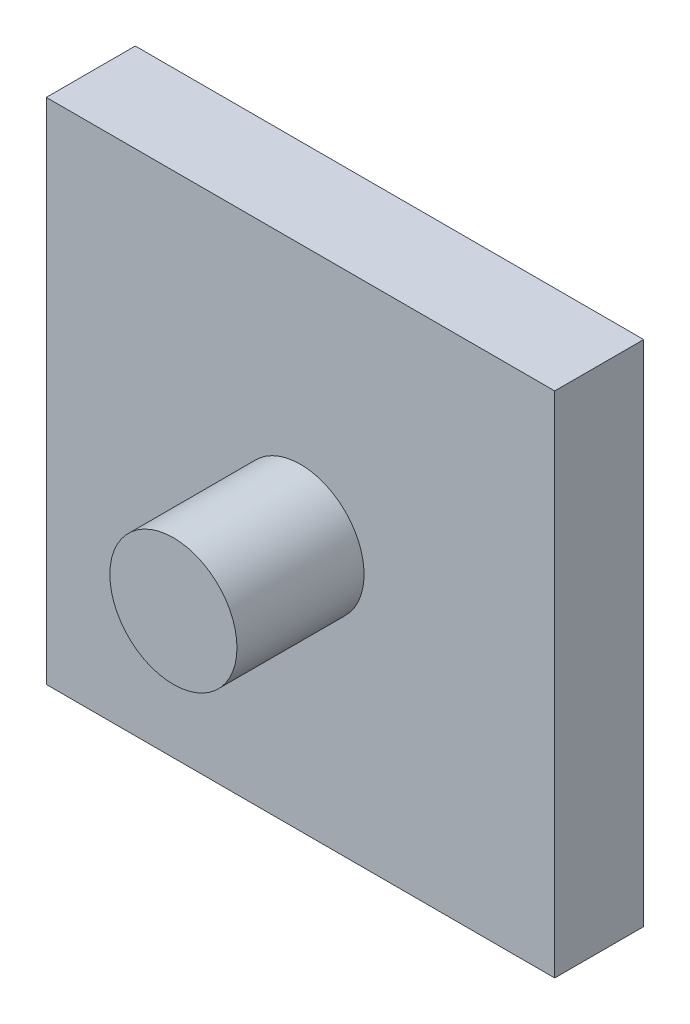
from build123d import *

# Parameters (mm, degrees)
ESQUISSE1_W        = 40
ESQUISSE1_H        = 40
BOSS_EXTRU_1_DEPTH = 7
ESQUISSE2_R        = 5
BOSS_EXTRU_2_DEPTH = 10


with BuildPart() as part:
    # Esquisse1 → Boss.-Extru.1 (new body)
    with BuildSketch(Plane.XY):
        Rectangle(ESQUISSE1_W, ESQUISSE1_H)
    extrude(amount=BOSS_EXTRU_1_DEPTH)

    # Esquisse2 → Boss.-Extru.2 (add)
    with BuildSketch(Plane.XY.offset(7)):
        Circle(ESQUISSE2_R)
    extrude(amount=BOSS_EXTRU_2_DEPTH)


solid = part.part
